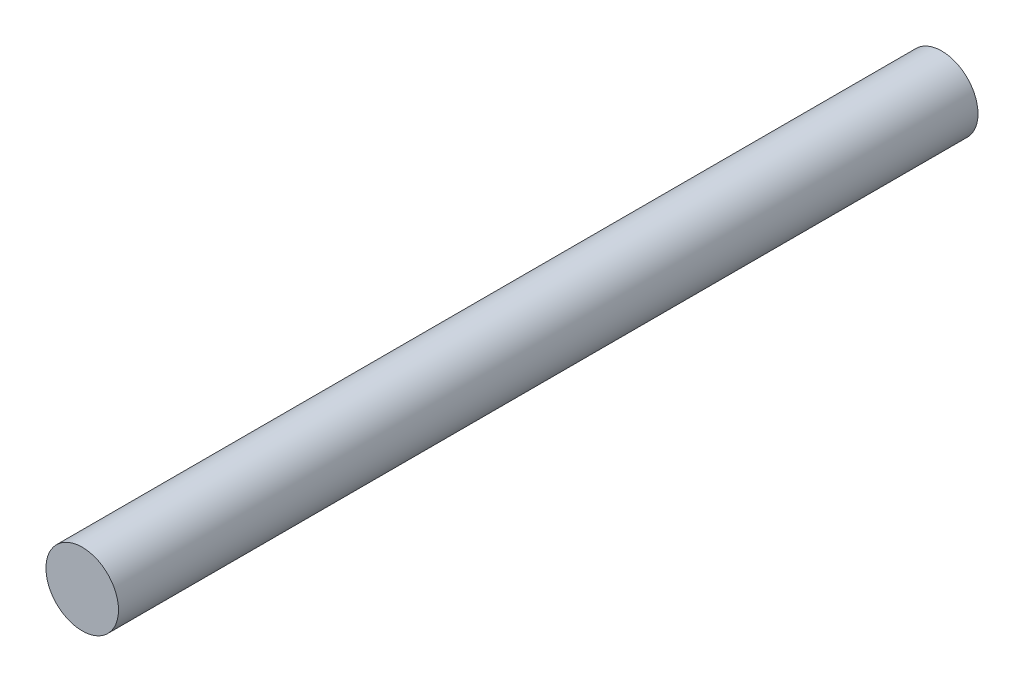
from build123d import *

# Parameters (mm, degrees)
SKETCH1_R           = 3.8
BOSS_EXTRUDE1_DEPTH = 90


with BuildPart() as part:
    # Sketch1 → Boss-Extrude1 (new body)
    with BuildSketch(Plane.XY):
        Circle(SKETCH1_R)
    extrude(amount=BOSS_EXTRUDE1_DEPTH)


solid = part.part
